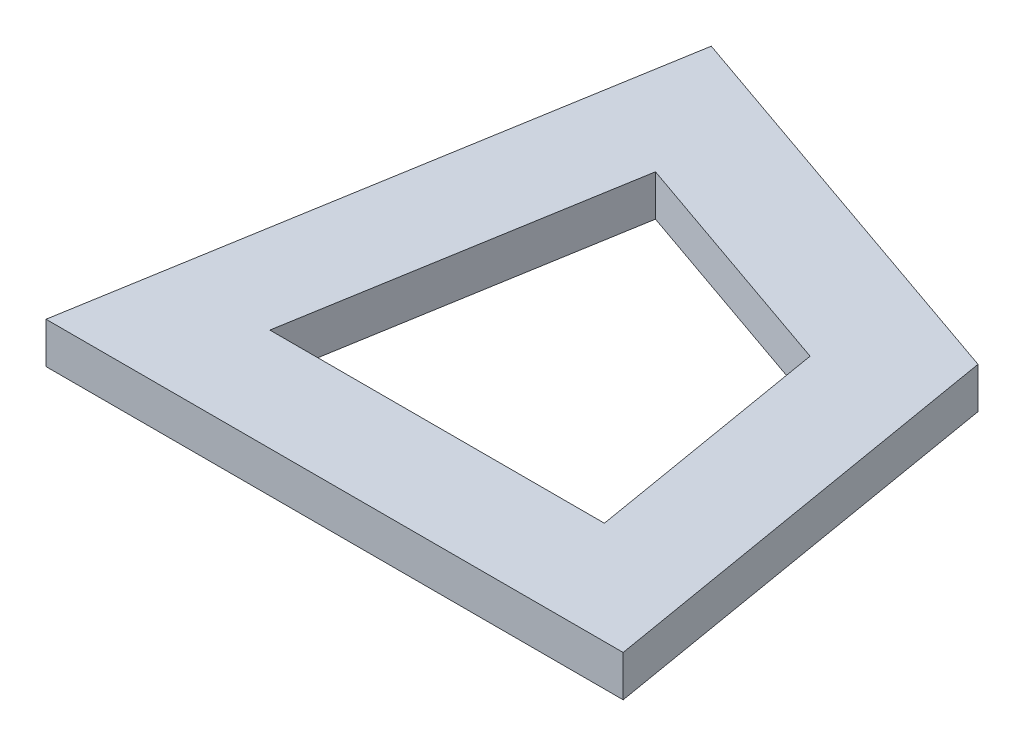
from build123d import *

# Parameters (mm, degrees)
BOSS_EXTRUDE1_DEPTH = 2


with BuildPart() as part:
    # Sketch1 → Boss-Extrude1 (new body)
    with BuildSketch(Plane(origin=(0, 0, 0), x_dir=(1, 0, 0), z_dir=(0, 1, 0))):
        Polygon((0, 0), (28.14318771, 0), (24.625630199, 20.819146034), (4.688560945, 27.749890283), align=None)
        Polygon((8.633349651, 21.08505535), (5.915653777, 5), (22.227533933, 5), (20.188531473, 17.0681154), align=None, mode=Mode.SUBTRACT)
    extrude(amount=BOSS_EXTRUDE1_DEPTH)


solid = part.part
